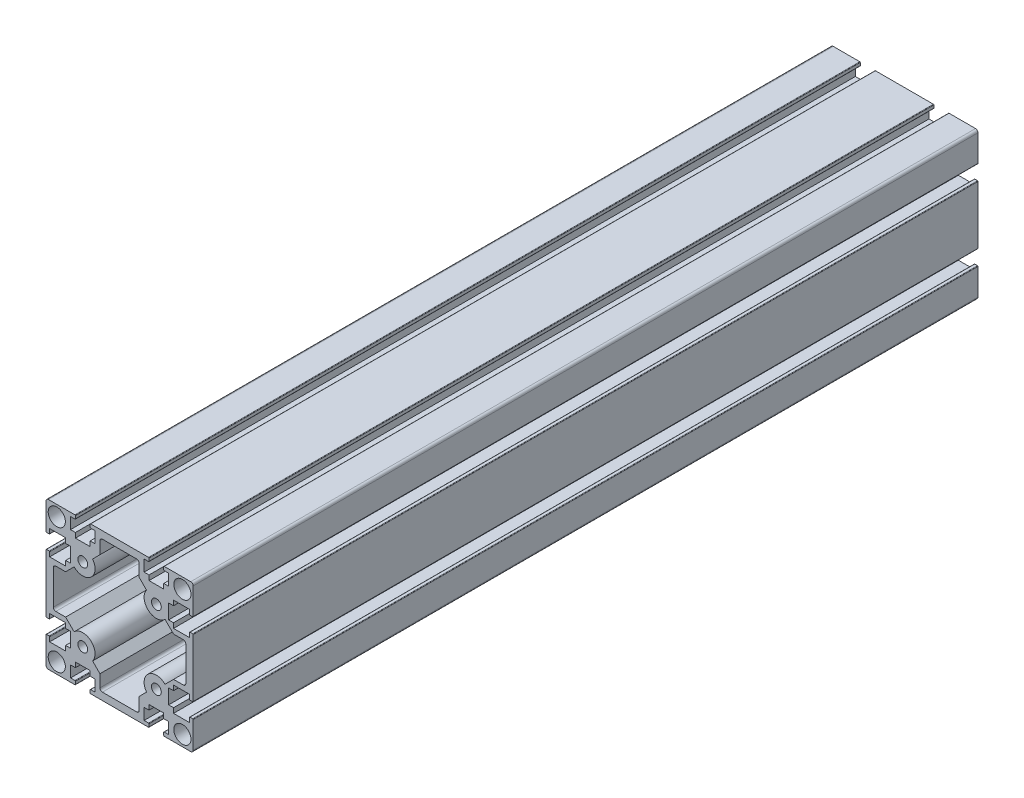
from build123d import *

# Parameters (mm, degrees)
SKETCH1_R           = 2
SKETCH1_R_2         = 3.5
BOSS_EXTRUDE1_DEPTH = 320
FILLET1_R           = 0.2
FILLET2_R           = 0.2


with BuildPart() as part:
    # Sketch1 → Boss-Extrude1 (new body)
    with BuildSketch(Plane.XY):
        with BuildLine():
            Line((-5, 3), (-5, -3))
            Line((-5, -3), (-7, -3))
            Line((-7, -3), (-7, -5))
            Line((-7, -5), (-13.5, -5))
            Line((-13.5, -5), (-13.5, -3))
            Line((-13.5, -3), (-15, -3))
            Line((-15, -3), (-15, -27))
            Line((-15, -27), (-13.5, -27))
            Line((-13.5, -27), (-13.5, -25))
            Line((-13.5, -25), (-7, -25))
            Line((-7, -25), (-7, -27))
            Line((-7, -27), (-5, -27))
            Line((-5, -27), (-5, -33))
            Line((-5, -33), (-7, -33))
            Line((-7, -33), (-7, -35))
            Line((-7, -35), (-13.5, -35))
            Line((-13.5, -35), (-13.5, -33))
            Line((-13.5, -33), (-15, -33))
            Line((-15, -33), (-15, -44))
            ThreePointArc((-15, -44), (-14.707106781, -44.707106781), (-14, -45))
            Line((-14, -45), (-3, -45))
            Line((-3, -45), (-3, -43.5))
            Line((-3, -43.5), (-5, -43.5))
            Line((-5, -43.5), (-5, -38.87437693))
            Line((-5, -38.87437693), (-3, -38.87437693))
            Line((-3, -38.87437693), (-3, -36.87437693))
            Line((-3, -36.87437693), (3, -36.87437693))
            Line((3, -36.87437693), (3, -38.87437693))
            Line((3, -38.87437693), (5, -38.87437693))
            Line((5, -38.87437693), (5, -43.5))
            Line((5, -43.5), (3, -43.5))
            Line((3, -43.5), (3, -45))
            Line((3, -45), (27, -45))
            Line((27, -45), (27, -43.5))
            Line((27, -43.5), (25, -43.5))
            Line((25, -43.5), (25, -38.87437693))
            Line((25, -38.87437693), (27, -38.87437693))
            Line((27, -38.87437693), (27, -36.87437693))
            Line((27, -36.87437693), (33, -36.87437693))
            Line((33, -36.87437693), (33, -38.87437693))
            Line((33, -38.87437693), (35, -38.87437693))
            Line((35, -38.87437693), (35, -43.5))
            Line((35, -43.5), (33, -43.5))
            Line((33, -43.5), (33, -45))
            Line((33, -45), (44, -45))
            ThreePointArc((44, -45), (44.707106781, -44.707106781), (45, -44))
            Line((45, -44), (45, -33))
            Line((45, -33), (43.5, -33))
            Line((43.5, -33), (43.5, -35))
            Line((43.5, -35), (37, -35))
            Line((37, -35), (37, -33))
            Line((37, -33), (35, -33))
            Line((35, -33), (35, -27))
            Line((35, -27), (37, -27))
            Line((37, -27), (37, -25))
            Line((37, -25), (43.5, -25))
            Line((43.5, -25), (43.5, -27))
            Line((43.5, -27), (45, -27))
            Line((45, -27), (45, -3))
            Line((45, -3), (43.5, -3))
            Line((43.5, -3), (43.5, -5))
            Line((43.5, -5), (37, -5))
            Line((37, -5), (37, -3))
            Line((37, -3), (35, -3))
            Line((35, -3), (35, 3))
            Line((35, 3), (37, 3))
            Line((37, 3), (37, 5))
            Line((37, 5), (43.5, 5))
            Line((43.5, 5), (43.5, 3))
            Line((43.5, 3), (45, 3))
            Line((45, 3), (45, 14))
            ThreePointArc((45, 14), (44.707106781, 14.707106781), (44, 15))
            Line((44, 15), (33, 15))
            Line((33, 15), (33, 13.5))
            Line((33, 13.5), (35, 13.5))
            Line((35, 13.5), (35, 8.87437693))
            Line((35, 8.87437693), (33, 8.87437693))
            Line((33, 8.87437693), (33, 6.87437693))
            Line((33, 6.87437693), (27, 6.87437693))
            Line((27, 6.87437693), (27, 8.87437693))
            Line((27, 8.87437693), (25, 8.87437693))
            Line((25, 8.87437693), (25, 13.5))
            Line((25, 13.5), (27, 13.5))
            Line((27, 13.5), (27, 15))
            Line((27, 15), (3, 15))
            Line((3, 15), (3, 13.5))
            Line((3, 13.5), (5, 13.5))
            Line((5, 13.5), (5, 8.87437693))
            Line((5, 8.87437693), (3, 8.87437693))
            Line((3, 8.87437693), (3, 6.87437693))
            Line((3, 6.87437693), (-3, 6.87437693))
            Line((-3, 6.87437693), (-3, 8.87437693))
            Line((-3, 8.87437693), (-5, 8.87437693))
            Line((-5, 8.87437693), (-5, 13.5))
            Line((-5, 13.5), (-3, 13.5))
            Line((-3, 13.5), (-3, 15))
            Line((-3, 15), (-14, 15))
            ThreePointArc((-14, 15), (-14.707106781, 14.707106781), (-15, 14))
            Line((-15, 14), (-15, 3))
            Line((-15, 3), (-13.5, 3))
            Line((-13.5, 3), (-13.5, 5))
            Line((-13.5, 5), (-7, 5))
            Line((-7, 5), (-7, 3))
            Line((-7, 3), (-5, 3))
        make_face()
        Circle(SKETCH1_R, mode=Mode.SUBTRACT)
        with Locations((-10.606601718, 10.606601718)):
            Circle(SKETCH1_R_2, mode=Mode.SUBTRACT)
        with Locations((-10.606601718, -40.606601718)):
            Circle(SKETCH1_R_2, mode=Mode.SUBTRACT)
        with Locations((0, -30)):
            Circle(SKETCH1_R, mode=Mode.SUBTRACT)
        with Locations((40.606601718, 10.606601718)):
            Circle(SKETCH1_R_2, mode=Mode.SUBTRACT)
        with Locations((30, 0)):
            Circle(SKETCH1_R, mode=Mode.SUBTRACT)
        with Locations((30, -30)):
            Circle(SKETCH1_R, mode=Mode.SUBTRACT)
        with Locations((40.606601718, -40.606601718)):
            Circle(SKETCH1_R_2, mode=Mode.SUBTRACT)
        with BuildLine():
            Line((7, 6), (4, 3))
            ThreePointArc((4, 3), (3.276008707, -3.777269775), (-3.535533906, -3.535533906))
            Line((-3.535533906, -3.535533906), (-7, -7))
            Line((-7, -7), (-11, -7))
            ThreePointArc((-11, -7), (-11.707106781, -7.292893219), (-12, -8))
            Line((-12, -8), (-12, -22))
            ThreePointArc((-12, -22), (-11.707106781, -22.707106781), (-11, -23))
            Line((-11, -23), (-7, -23))
            Line((-7, -23), (-3.535533906, -26.464466094))
            ThreePointArc((-3.535533906, -26.464466094), (3.276008707, -26.222730225), (4, -33))
            Line((4, -33), (7, -36))
            Line((7, -36), (7, -41))
            ThreePointArc((7, -41), (7.292893219, -41.707106781), (8, -42))
            Line((8, -42), (22, -42))
            ThreePointArc((22, -42), (22.707106781, -41.707106781), (23, -41))
            Line((23, -41), (23, -36))
            Line((23, -36), (26, -33))
            ThreePointArc((26, -33), (26.723991293, -26.222730225), (33.535533906, -26.464466094))
            Line((33.535533906, -26.464466094), (37, -23))
            Line((37, -23), (41, -23))
            ThreePointArc((41, -23), (41.707106781, -22.707106781), (42, -22))
            Line((42, -22), (42, -8))
            ThreePointArc((42, -8), (41.707106781, -7.292893219), (41, -7))
            Line((41, -7), (37, -7))
            Line((37, -7), (33.535533906, -3.535533906))
            ThreePointArc((33.535533906, -3.535533906), (26.723991293, -3.777269775), (26, 3))
            Line((26, 3), (23, 6))
            Line((23, 6), (23, 11))
            ThreePointArc((23, 11), (22.707106781, 11.707106781), (22, 12))
            Line((22, 12), (8, 12))
            ThreePointArc((8, 12), (7.292893219, 11.707106781), (7, 11))
            Line((7, 11), (7, 6))
        make_face(mode=Mode.SUBTRACT)
    extrude(amount=BOSS_EXTRUDE1_DEPTH)

    # Fillet1
    fillet1_edges = [part.edges().sort_by_distance(p)[0] for p in [
        (-15, 3, 160),
        (-3, 15, 160),
        (3, 15, 160),
        (27, 15, 160),
        (33, 15, 160),
        (45, 3, 160),
        (45, -3, 160),
        (45, -27, 160),
        (45, -33, 160),
        (33, -45, 160),
        (27, -45, 160),
        (3, -45, 160),
        (-3, -45, 160),
        (-15, -33, 160),
        (-15, -27, 160),
        (-15, -3, 160),
    ]]
    fillet(fillet1_edges, radius=FILLET1_R)

    # Fillet2
    fillet2_edges = [part.edges().sort_by_distance(p)[0] for p in [
        (-13.5, 3, 160),
        (-3, 13.5, 160),
        (3, 13.5, 160),
        (27, 13.5, 160),
        (33, 13.5, 160),
        (43.5, 3, 160),
        (43.5, -3, 160),
        (43.5, -27, 160),
        (43.5, -33, 160),
        (33, -43.5, 160),
        (27, -43.5, 160),
        (3, -43.5, 160),
        (-3, -43.5, 160),
        (-13.5, -33, 160),
        (-13.5, -27, 160),
        (-13.5, -3, 160),
    ]]
    fillet(fillet2_edges, radius=FILLET2_R)


solid = part.part
